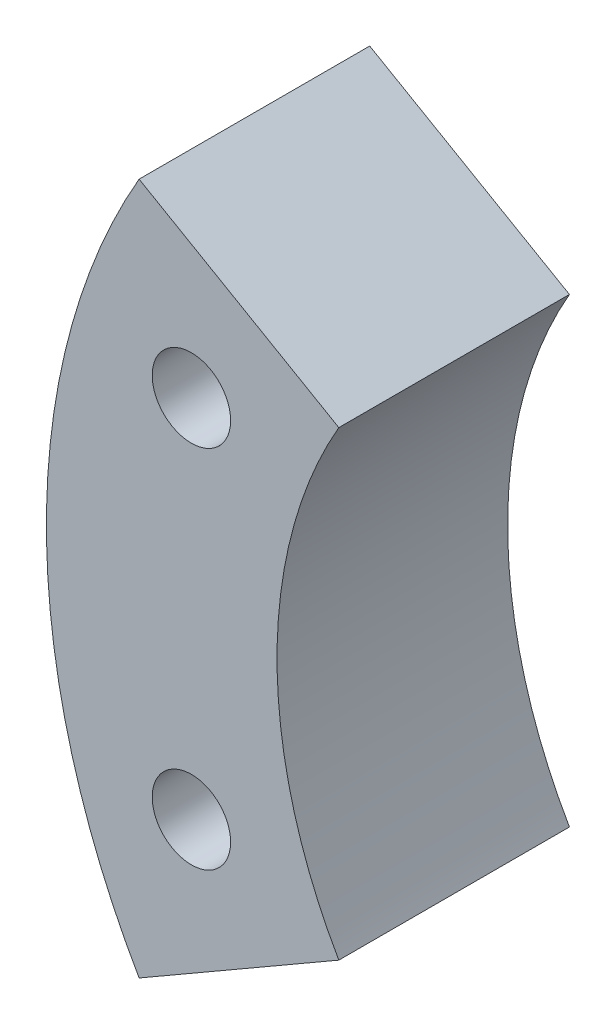
from build123d import *

# Parameters (mm, degrees)
BOSS_EXTRUDE1_DEPTH = 6.35
CUT_EXTRUDE1_REACH  = 8.35
SKETCH2_R           = 1.0795


with BuildPart() as part:
    # Sketch1 → Boss-Extrude1 (new body)
    with BuildSketch(Plane(origin=(0, 0, 0), x_dir=(0, 1, 0), z_dir=(0, 0, 1))):
        with BuildLine():
            Line((-9.525, 16.497783942), (-6.35, 10.998522628))
            ThreePointArc((-6.35, 10.998522628), (0, 12.7), (6.35, 10.998522628))
            Line((6.35, 10.998522628), (9.525, 16.497783942))
            ThreePointArc((9.525, 16.497783942), (0, 19.05), (-9.525, 16.497783942))
        make_face()
    extrude(amount=BOSS_EXTRUDE1_DEPTH)

    # Sketch2 → Cut-Extrude1 (cut, up to next)
    with BuildSketch(Plane.XY.offset(6.35), mode=Mode.PRIVATE) as cut_extrude1_sk1:
        with Locations((-15.057884182, 5.027499276)):
            Circle(SKETCH2_R)
    cut_extrude1_tool1 = extrude(cut_extrude1_sk1.sketch, amount=-CUT_EXTRUDE1_REACH, mode=Mode.PRIVATE) & part.part
    add(cut_extrude1_tool1.solids().sort_by_distance((-15.057884, 5.027499, 6.35))[0], mode=Mode.SUBTRACT)
    # Sketch2 → Cut-Extrude1 (cut, up to next)
    with BuildSketch(Plane.XY.offset(6.35), mode=Mode.PRIVATE) as cut_extrude1_sk2:
        with Locations((-15.057884182, -5.027499276)):
            Circle(SKETCH2_R)
    cut_extrude1_tool2 = extrude(cut_extrude1_sk2.sketch, amount=-CUT_EXTRUDE1_REACH, mode=Mode.PRIVATE) & part.part
    add(cut_extrude1_tool2.solids().sort_by_distance((-15.057884, -5.027499, 6.35))[0], mode=Mode.SUBTRACT)


solid = part.part
